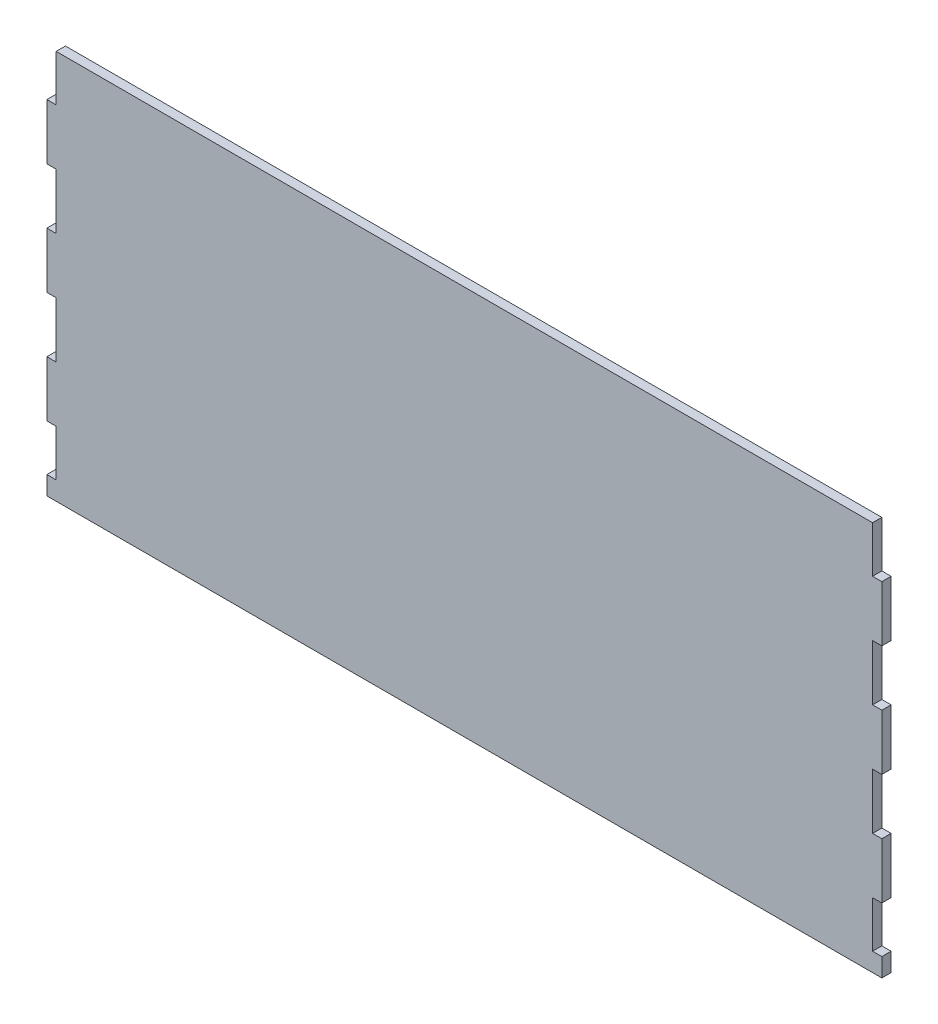
from build123d import *

# Parameters (mm, degrees)
SKETCH1_W           = 450
SKETCH1_H           = 210
BOSS_EXTRUDE1_DEPTH = 5
SKETCH3_W           = 65.821391225
SKETCH3_H           = 25
SKETCH3_W_2         = 143.228691138
SKETCH3_H_2         = 30
SKETCH3_W_3         = 192.205874683
SKETCH3_W_4         = 194.707934706
SKETCH3_W_5         = 70.821391225
SKETCH3_W_6         = 148.228691138
SKETCH3_W_7         = 194.705874683
SKETCH3_W_8         = 199.707934706
CUT_EXTRUDE1_DEPTH  = 6


with BuildPart() as part:
    # Sketch1 → Boss-Extrude1 (new body)
    with BuildSketch(Plane.XY):
        Rectangle(SKETCH1_W, SKETCH1_H)
    extrude(amount=BOSS_EXTRUDE1_DEPTH)

    # Sketch3 → Cut-Extrude1 (cut, through all)
    with BuildSketch(Plane(origin=(0, 0, 0), x_dir=(-1, 0, 0), z_dir=(0, 0, -1))):
        with Locations((-252.910695613, 92.5)):
            Rectangle(SKETCH3_W, SKETCH3_H)
        with Locations((-291.614345569, 35)):
            Rectangle(SKETCH3_W_2, SKETCH3_H_2)
        with Locations((-316.102937342, -25)):
            Rectangle(SKETCH3_W_3, SKETCH3_H_2)
        with Locations((-317.353967353, -82.5)):
            Rectangle(SKETCH3_W_4, SKETCH3_H)
        with Locations((255.410695613, 92.5)):
            Rectangle(SKETCH3_W_5, SKETCH3_H)
        with Locations((294.114345569, 35)):
            Rectangle(SKETCH3_W_6, SKETCH3_H_2)
        with Locations((317.352937342, -25)):
            Rectangle(SKETCH3_W_7, SKETCH3_H_2)
        with Locations((319.853967353, -82.5)):
            Rectangle(SKETCH3_W_8, SKETCH3_H)
    extrude(amount=-CUT_EXTRUDE1_DEPTH, mode=Mode.SUBTRACT)


solid = part.part
